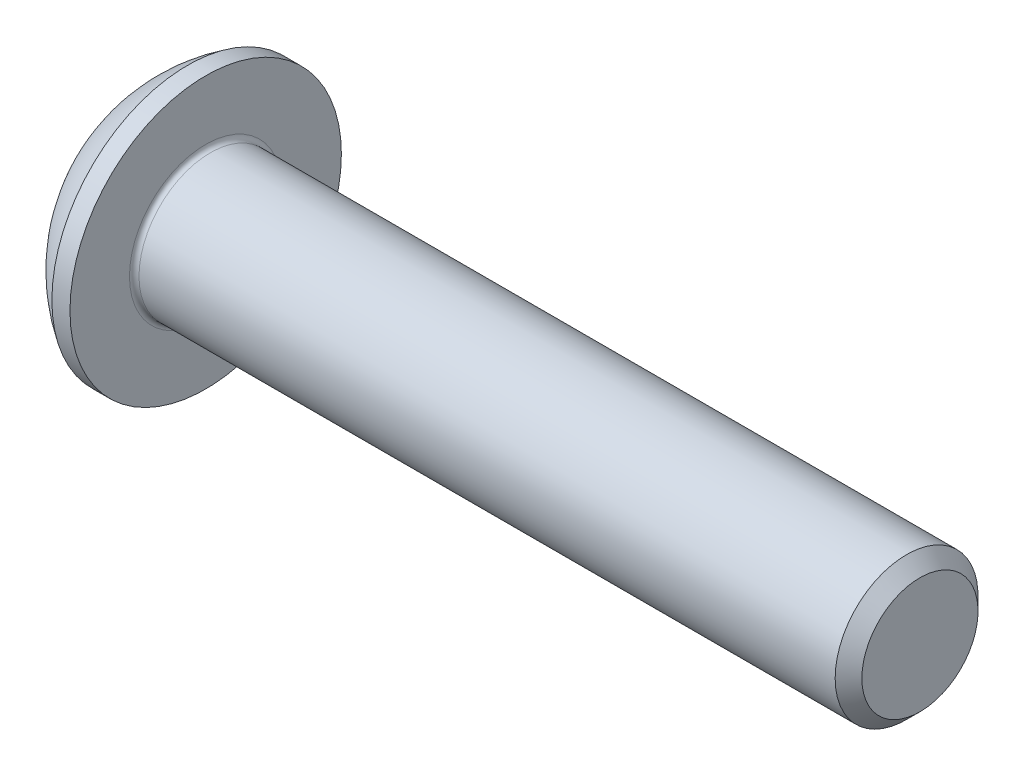
from build123d import *

# Parameters (mm, degrees)
FILLET1_R   = 0.1
HEX_2_DEPTH = 1.04


with BuildPart() as part:
    # BodySke → BaseBody (revolve)
    with BuildSketch(Plane.XY):
        with BuildLine():
            Line((16.65, 0), (16.65, 1.2195))
            Line((16.65, 1.2195), (16.3695, 1.5))
            Line((16.3695, 1.5), (1.65, 1.5))
            Line((1.65, 1.5), (1.65, 2.85))
            Line((1.65, 2.85), (1.27, 2.85))
            ThreePointArc((1.27, 2.85), (0.53140404, 2.229827628), (0, 1.425))
            Line((0, 1.425), (0, 0))
            Line((0, 0), (16.65, 0))
        make_face()
    revolve(axis=Axis((0, 0, 0), (1, 0, 0)))

    # Fillet1
    fillet1_edges = [part.edges().sort_by_distance(p)[0] for p in [
        (1.65, -1.5, 0),
    ]]
    fillet(fillet1_edges, radius=FILLET1_R)

    # Sketch2 → PreBroach (revolve, cut)
    with BuildSketch(Plane.XY):
        Polygon((0, 1), (1.04, 1), (1.617350269, 0), (0, 0), align=None)
    revolve(axis=Axis((0, 0, 0), (1, 0, 0)), mode=Mode.SUBTRACT)

    # Sketch3 → Hex 2 (cut)
    with BuildSketch(Plane(origin=(0, 0, 0), x_dir=(0, 0, -1), z_dir=(1, 0, 0))):
        Polygon((-1, -0.577350269), (-1, 0.577350269), (0, 1.154700538), (1, 0.577350269), (1, -0.577350269), (0, -1.154700538), align=None)
    extrude(amount=HEX_2_DEPTH, mode=Mode.SUBTRACT)


solid = part.part
